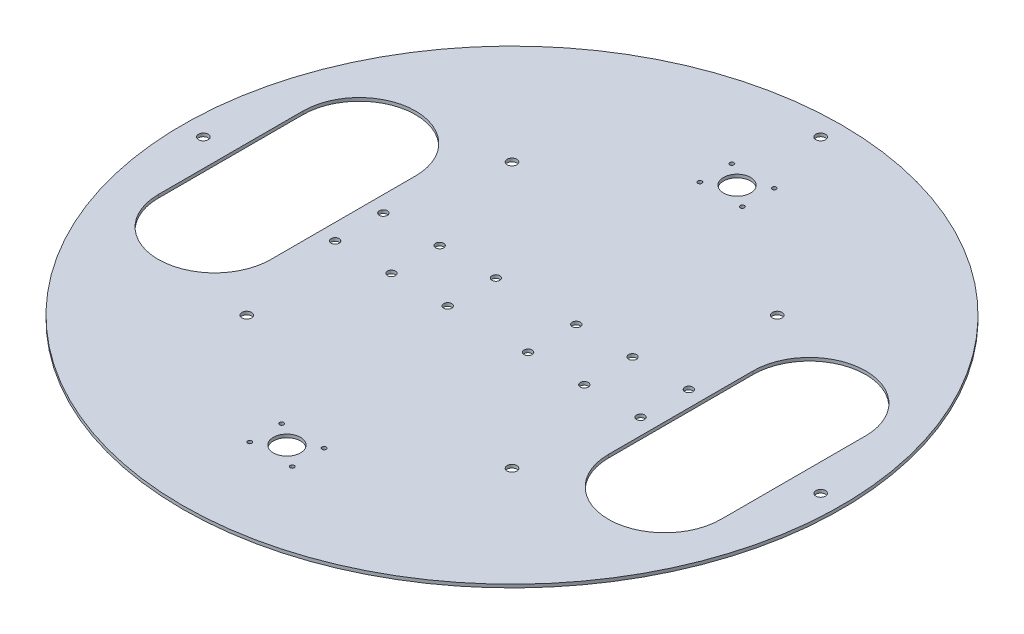
from build123d import *

# Parameters (mm, degrees)
SKETCH1_R               = 205
SKETCH1_R_2             = 8.425
SKETCH1_R_3             = 1.31
SKETCH1_R_4             = 3
BOSS_EXTRUDE1_DEPTH     = 2
SKETCH2_R               = 3
CUT_EXTRUDE1_DEPTH      = 1
CUT_EXTRUDE1_DEPTH_BACK = 3
SKETCH3_R               = 2.5
CUT_EXTRUDE2_DEPTH      = 10


with BuildPart() as part:
    # Sketch1 → Boss-Extrude1 (new body)
    with BuildSketch(Plane(origin=(0, 0, 0), x_dir=(1, 0, 0), z_dir=(0, 1, 0))):
        Circle(SKETCH1_R)
        with Locations((0, 140)):
            Circle(SKETCH1_R_2, mode=Mode.SUBTRACT)
        with Locations((0, -140)):
            Circle(SKETCH1_R_2, mode=Mode.SUBTRACT)
        with Locations((-13.2, 149.92)):
            Circle(SKETCH1_R_3, mode=Mode.SUBTRACT)
        with Locations((13.2, 149.92)):
            Circle(SKETCH1_R_3, mode=Mode.SUBTRACT)
        with Locations((13.2, 130.08)):
            Circle(SKETCH1_R_3, mode=Mode.SUBTRACT)
        with Locations((-13.2, 130.08)):
            Circle(SKETCH1_R_3, mode=Mode.SUBTRACT)
        with Locations((-13.2, -130.08)):
            Circle(SKETCH1_R_3, mode=Mode.SUBTRACT)
        with Locations((13.2, -130.08)):
            Circle(SKETCH1_R_3, mode=Mode.SUBTRACT)
        with Locations((13.2, -149.92)):
            Circle(SKETCH1_R_3, mode=Mode.SUBTRACT)
        with Locations((-13.2, -149.92)):
            Circle(SKETCH1_R_3, mode=Mode.SUBTRACT)
        with Locations((-82.5, 82.5)):
            Circle(SKETCH1_R_4, mode=Mode.SUBTRACT)
        with Locations((82.5, 82.5)):
            Circle(SKETCH1_R_4, mode=Mode.SUBTRACT)
        with Locations((82.5, -82.5)):
            Circle(SKETCH1_R_4, mode=Mode.SUBTRACT)
        with Locations((-82.5, -82.5)):
            Circle(SKETCH1_R_4, mode=Mode.SUBTRACT)
        with BuildLine():
            Line((-105, 45), (-105, -45))
            ThreePointArc((-105, -45), (-140, -80), (-175, -45))
            Line((-175, -45), (-175, 45))
            ThreePointArc((-175, 45), (-140, 80), (-105, 45))
        make_face(mode=Mode.SUBTRACT)
        with BuildLine():
            Line((175, 45), (175, -45))
            ThreePointArc((175, -45), (140, -80), (105, -45))
            Line((105, -45), (105, 45))
            ThreePointArc((105, 45), (140, 80), (175, 45))
        make_face(mode=Mode.SUBTRACT)
    extrude(amount=BOSS_EXTRUDE1_DEPTH)

    # Sketch2 → Cut-Extrude1 (cut, two sides)
    with BuildSketch(Plane(origin=(0, 2, 0), x_dir=(1, 0, 0), z_dir=(0, 1, 0))) as cut_extrude1_sk:
        with Locations((0, 192)):
            Circle(SKETCH2_R)
        with Locations((192, 0)):
            Circle(SKETCH2_R)
        with Locations((-192, 0)):
            Circle(SKETCH2_R)
    extrude(amount=CUT_EXTRUDE1_DEPTH, mode=Mode.SUBTRACT)
    extrude(cut_extrude1_sk.sketch, amount=-CUT_EXTRUDE1_DEPTH_BACK, mode=Mode.SUBTRACT)

    # Sketch3 → Cut-Extrude2 (cut)
    with BuildSketch(Plane(origin=(0, 2, 0), x_dir=(1, 0, 0), z_dir=(0, 1, 0))):
        with Locations((95, 15)):
            Circle(SKETCH3_R)
        with Locations((95, -15)):
            Circle(SKETCH3_R)
        with Locations((60, -15)):
            Circle(SKETCH3_R)
        with Locations((25, -15)):
            Circle(SKETCH3_R)
        with Locations((25, 15)):
            Circle(SKETCH3_R)
        with Locations((60, 15)):
            Circle(SKETCH3_R)
        with Locations((-60, 15)):
            Circle(SKETCH3_R)
        with Locations((-25, 15)):
            Circle(SKETCH3_R)
        with Locations((-25, -15)):
            Circle(SKETCH3_R)
        with Locations((-60, -15)):
            Circle(SKETCH3_R)
        with Locations((-95, -15)):
            Circle(SKETCH3_R)
        with Locations((-95, 15)):
            Circle(SKETCH3_R)
    extrude(amount=-CUT_EXTRUDE2_DEPTH, mode=Mode.SUBTRACT)


solid = part.part
